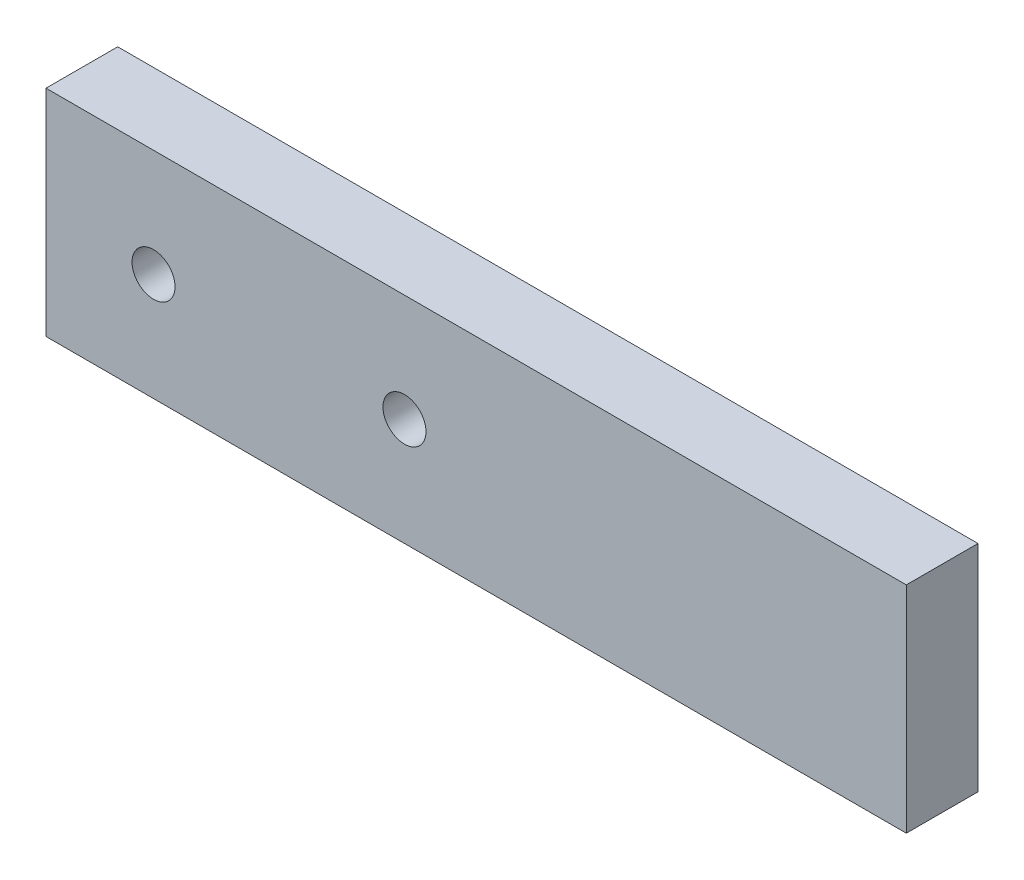
from build123d import *

# Parameters (mm, degrees)
SKETCH1_W           = 60
SKETCH1_H           = 15
SKETCH1_R           = 1.5
BOSS_EXTRUDE1_DEPTH = 5


with BuildPart() as part:
    # Sketch1 → Boss-Extrude1 (new body)
    with BuildSketch(Plane.XY):
        with Locations((-30, 7.5)):
            Rectangle(SKETCH1_W, SKETCH1_H)
        with Locations((-52.5, 7.5)):
            Circle(SKETCH1_R, mode=Mode.SUBTRACT)
        with Locations((-35, 7.5)):
            Circle(SKETCH1_R, mode=Mode.SUBTRACT)
    extrude(amount=BOSS_EXTRUDE1_DEPTH)


solid = part.part
